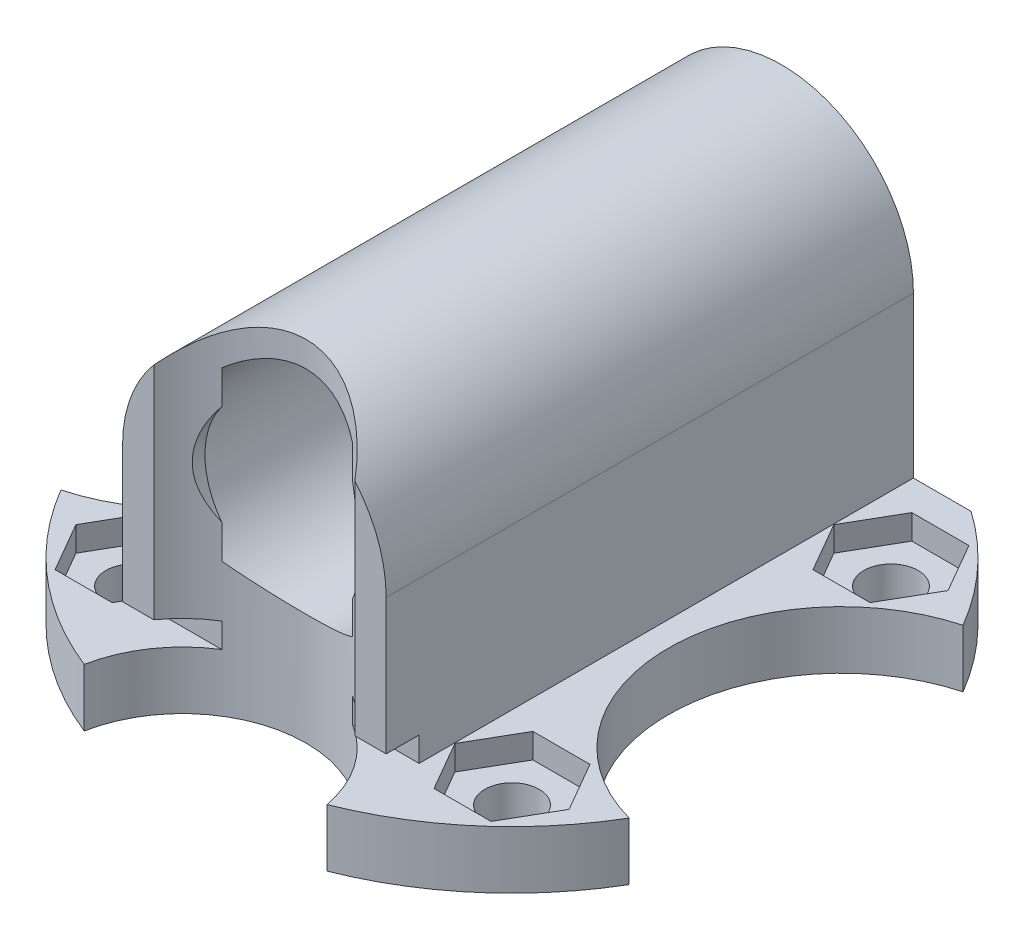
from build123d import *

# Parameters (mm, degrees)
SKETCH1_R               = 20
SKETCH1_R_2             = 1.65
BOSS_EXTRUDE2_DEPTH     = 3.5
CUT_EXTRUDE1_DEPTH      = 44.26420678
CUT_EXTRUDE1_DEPTH_BACK = 44.26420678
SKETCH4_R               = 6.45
BOSS_EXTRUDE3_DEPTH     = 30
SKETCH5_R               = 5
BOSS_EXTRUDE4_DEPTH     = 2
CUT_EXTRUDE2_START      = -3.5
CUT_EXTRUDE2_DEPTH      = 1.5
SKETCH7_R               = 10.5
SKETCH7_R_2             = 7.5
CUT_EXTRUDE3_DEPTH      = 46.990141289


with BuildPart() as part:
    # Sketch1 → Boss-Extrude2 (new body)
    with BuildSketch(Plane(origin=(0, 0, 0), x_dir=(1, 0, 0), z_dir=(0, 1, 0))):
        with Locations((-12.255661444, 8.620165848)):
            Circle(SKETCH1_R)
        with Locations((-23.755661444, 20.120165848)):
            Circle(SKETCH1_R_2, mode=Mode.SUBTRACT)
        with Locations((-0.755661444, 20.120165848)):
            Circle(SKETCH1_R_2, mode=Mode.SUBTRACT)
        with Locations((-23.755661444, -2.879834152)):
            Circle(SKETCH1_R_2, mode=Mode.SUBTRACT)
        with Locations((-0.755661444, -2.879834152)):
            Circle(SKETCH1_R_2, mode=Mode.SUBTRACT)
    extrude(amount=BOSS_EXTRUDE2_DEPTH)

    # Sketch3 → Cut-Extrude1 (cut, two sides: drawn at the far end of the back side and taken through both)
    with BuildSketch(Plane(origin=(0, 3.5, 0), x_dir=(1, 0, 0), z_dir=(0, 1, 0)).offset(-CUT_EXTRUDE1_DEPTH_BACK)):
        Polygon((-129.974635183, 24.98323402), (-23.755661444, 24.98323402), (-0.755661444, 24.98323402), (105.463312296, 24.98323402), (105.463312296, 237.421181499), (-129.974635183, 237.421181499), align=None)
    extrude(amount=CUT_EXTRUDE1_DEPTH + CUT_EXTRUDE1_DEPTH_BACK, mode=Mode.SUBTRACT)

    # Sketch4 → Boss-Extrude3 (add)
    with BuildSketch(Plane(origin=(0, 0, -24.98323402), x_dir=(-1, 0, 0), z_dir=(0, 0, -1))):
        with BuildLine():
            Line((4.255661444, 13.225065807), (4.255661444, 3.5))
            Line((4.255661444, 3.5), (20.255661444, 3.5))
            Line((20.255661444, 3.5), (20.255661444, 13.225065807))
            ThreePointArc((20.255661444, 13.225065807), (12.255661444, 21.225065807), (4.255661444, 13.225065807))
        make_face()
        with Locations((12.255661444, 13.225065807)):
            Circle(SKETCH4_R, mode=Mode.SUBTRACT)
    extrude(amount=-BOSS_EXTRUDE3_DEPTH)

    # Sketch5 → Boss-Extrude4 (add)
    with BuildSketch(Plane.XY.offset(5.01676598)):
        with BuildLine():
            Line((-20.255661444, 13.225065807), (-20.255661444, 5))
            Line((-20.255661444, 5), (-4.255661444, 5))
            Line((-4.255661444, 5), (-4.255661444, 13.225065807))
            ThreePointArc((-4.255661444, 13.225065807), (-12.255661444, 21.225065807), (-20.255661444, 13.225065807))
        make_face()
        with Locations((-12.255661444, 13.225065807)):
            Circle(SKETCH5_R, mode=Mode.SUBTRACT)
    extrude(amount=BOSS_EXTRUDE4_DEPTH)

    # Sketch6 → Cut-Extrude2 (cut)
    with BuildSketch(Plane.XZ.offset(CUT_EXTRUDE2_START)):
        Polygon((-22.023610636, -17.120165848), (-25.487712251, -17.120165848), (-27.219763059, -20.120165848), (-25.487712251, -23.120165848), (-22.023610636, -23.120165848), (-20.291559828, -20.120165848), align=None)
        Polygon((-22.023610636, -0.120165848), (-20.291559828, 2.879834152), (-22.023610636, 5.879834152), (-25.487712251, 5.879834152), (-27.219763059, 2.879834152), (-25.487712251, -0.120165848), align=None)
        Polygon((0.976389364, -0.120165848), (2.708440172, 2.879834152), (0.976389364, 5.879834152), (-2.487712251, 5.879834152), (-4.219763059, 2.879834152), (-2.487712251, -0.120165848), align=None)
        Polygon((0.976389364, -17.120165848), (-2.487712251, -17.120165848), (-4.219763059, -20.120165848), (-2.487712251, -23.120165848), (0.976389364, -23.120165848), (2.708440172, -20.120165848), align=None)
    extrude(amount=CUT_EXTRUDE2_DEPTH, mode=Mode.SUBTRACT)

    # Sketch7 → Cut-Extrude3 (cut, through all)
    with BuildSketch(Plane.XZ):
        with Locations((-32.255661444, -8.620165848)):
            Circle(SKETCH7_R)
        with Locations((7.744338556, -8.620165848)):
            Circle(SKETCH7_R)
        with Locations((-12.255661444, 11.379834152)):
            Circle(SKETCH7_R_2)
    extrude(amount=-CUT_EXTRUDE3_DEPTH, mode=Mode.SUBTRACT)


solid = part.part
